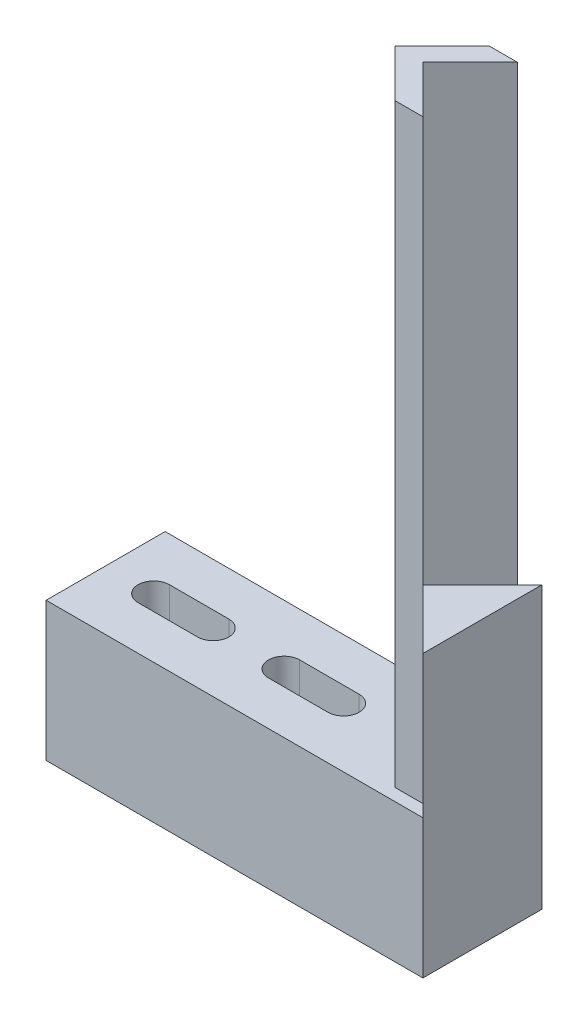
from build123d import *

# Parameters (mm, degrees)
SKETCH1_W           = 48.26
SKETCH1_H           = 17.78
BOSS_EXTRUDE1_DEPTH = 15.24
CUT_EXTRUDE2_DEPTH  = 54.641528688
BOSS_EXTRUDE2_DEPTH = 76.2
BOSS_EXTRUDE4_DEPTH = 18.21999912


with BuildPart() as part:
    # Sketch1 → Boss-Extrude1 (new body)
    with BuildSketch(Plane.XY):
        with Locations((24.13, 8.89)):
            Rectangle(SKETCH1_W, SKETCH1_H)
    extrude(amount=-BOSS_EXTRUDE1_DEPTH)

    # Sketch4 → Cut-Extrude2 (cut, through all)
    with BuildSketch(Plane(origin=(0, 17.78, 0), x_dir=(1, 0, 0), z_dir=(0, 1, 0))):
        with BuildLine():
            Line((30.48, 5.62), (22.86, 5.62))
            ThreePointArc((22.86, 5.62), (20.86, 7.62), (22.86, 9.62))
            Line((22.86, 9.62), (30.48, 9.62))
            ThreePointArc((30.48, 9.62), (32.48, 7.62), (30.48, 5.62))
        make_face()
        with BuildLine():
            Line((13.78, 5.62), (6.16, 5.62))
            ThreePointArc((6.16, 5.62), (4.16, 7.62), (6.16, 9.62))
            Line((6.16, 9.62), (13.78, 9.62))
            ThreePointArc((13.78, 9.62), (15.78, 7.62), (13.78, 5.62))
        make_face()
    extrude(amount=-CUT_EXTRUDE2_DEPTH, mode=Mode.SUBTRACT)

    # Sketch3 → Boss-Extrude2 (add)
    with BuildSketch(Plane(origin=(0, 17.78, 0), x_dir=(1, 0, 0), z_dir=(0, 1, 0))):
        Polygon((40.64, 7.62), (46.685762979, 13.665762979), (43.093660531, 13.665762979), (37.047897552, 7.62), (43.093660531, 1.574237021), (46.685762979, 1.574237021), align=None)
    extrude(amount=BOSS_EXTRUDE2_DEPTH)

    # Sketch3_7 → Boss-Extrude4 (add)
    with BuildSketch(Plane(origin=(0, 17.78, 0), x_dir=(1, 0, 0), z_dir=(0, 1, 0))):
        Polygon((48.26, 0), (48.26, 15.24), (46.685762979, 13.665762979), (40.64, 7.62), (46.685762979, 1.574237021), align=None)
    extrude(amount=BOSS_EXTRUDE4_DEPTH)


solid = part.part
